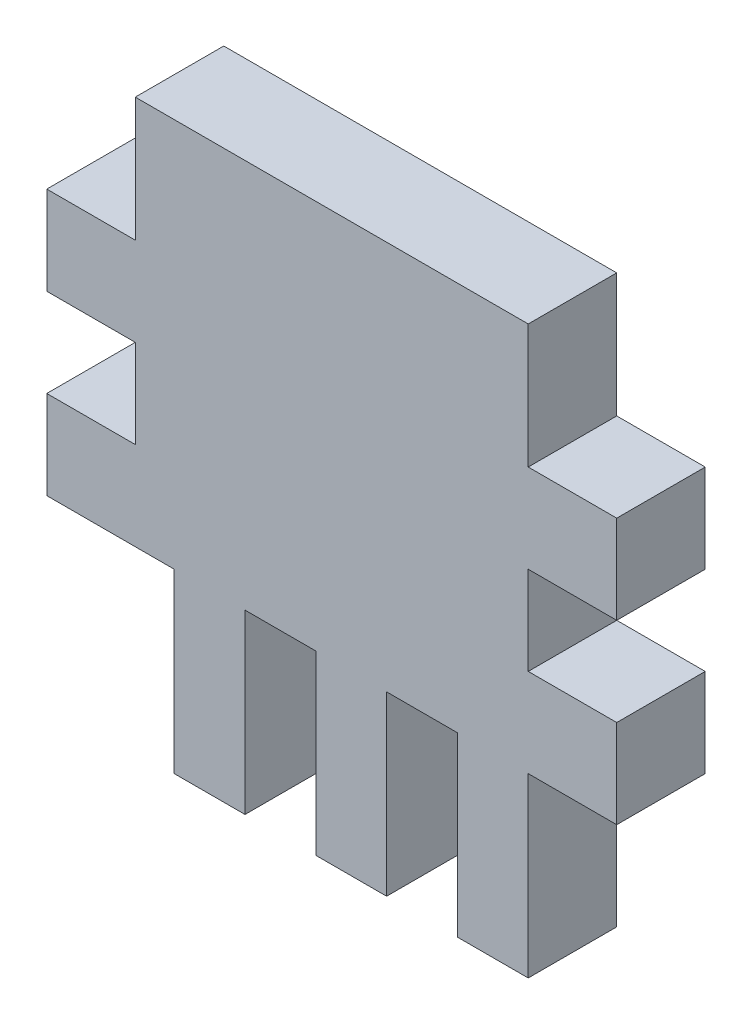
from build123d import *

# Parameters (mm, degrees)
BOSS_EXTRU_1_DEPTH = 5


with BuildPart() as part:
    # Esquisse2 → Boss.-Extru.1 (new body)
    with BuildSketch(Plane.XY):
        Polygon((1.360531515, 3.786938771), (-3.639468485, 3.786938771), (-3.639468485, -1.213061229), (3.560531515, -1.213061229), (3.560531515, -11.213061229), (7.560531515, -11.213061229), (7.560531515, -1.213061229), (11.560531515, -1.213061229), (11.560531515, -11.213061229), (15.560531515, -11.213061229), (15.560531515, -1.213061229), (19.560531515, -1.213061229), (19.560531515, -11.213061229), (23.560531515, -11.213061229), (23.560531515, -1.213061229), (28.560531515, -1.213061229), (28.560531515, 3.786938771), (23.560531515, 3.786938771), (23.560531515, 8.786938771), (28.560531515, 8.786938771), (28.560531515, 13.786938771), (23.560531515, 13.786938771), (23.560531515, 20.786938771), (1.360531515, 20.786938771), (1.360531515, 13.786938771), (-3.639468485, 13.786938771), (-3.639468485, 8.786938771), (1.360531515, 8.786938771), align=None)
    extrude(amount=BOSS_EXTRU_1_DEPTH)


solid = part.part
